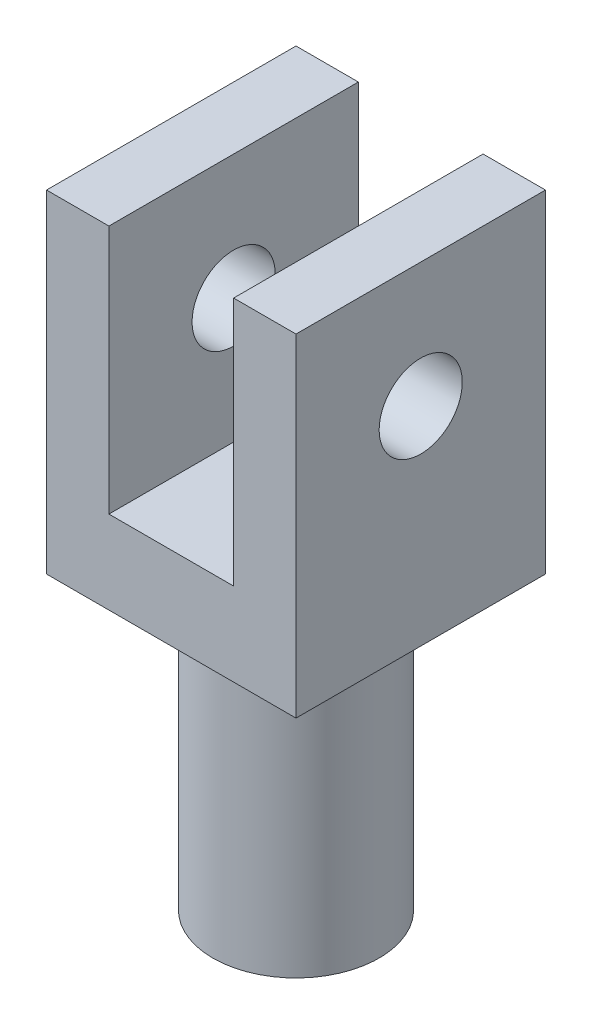
from build123d import *

# Parameters (mm, degrees)
ESQUISSE1_W             = 30
ESQUISSE1_H             = 40
BOSS_EXTRU_1_DEPTH      = 30
ESQUISSE2_W             = 15
ESQUISSE2_H             = 30
ENL_V_MAT_EXTRU_1_DEPTH = 30
ESQUISSE3_R             = 5
ENL_V_MAT_EXTRU_2_DEPTH = 50
ESQUISSE4_R             = 10
BOSS_EXTRU_2_DEPTH      = 35


with BuildPart() as part:
    # Esquisse1 → Boss.-Extru.1 (new body)
    with BuildSketch(Plane.XY):
        with Locations((-15, 20)):
            Rectangle(ESQUISSE1_W, ESQUISSE1_H)
    extrude(amount=BOSS_EXTRU_1_DEPTH)

    # Esquisse2 → Enlèv. mat.-Extru.1 (cut)
    with BuildSketch(Plane.XY.offset(30)):
        with Locations((-15, 25)):
            Rectangle(ESQUISSE2_W, ESQUISSE2_H)
    extrude(amount=-ENL_V_MAT_EXTRU_1_DEPTH, mode=Mode.SUBTRACT)

    # Esquisse3 → Enlèv. mat.-Extru.2 (cut)
    with BuildSketch(Plane.ZY.offset(30)):
        with Locations((15, 25)):
            Circle(ESQUISSE3_R)
    extrude(amount=-ENL_V_MAT_EXTRU_2_DEPTH, mode=Mode.SUBTRACT)

    # Esquisse4 → Boss.-Extru.2 (add)
    with BuildSketch(Plane.XZ):
        with Locations(Location((-15, 15, 0), (0, 0, 90))):  # turned: the seam where the file's is
            Circle(ESQUISSE4_R)
    extrude(amount=BOSS_EXTRU_2_DEPTH)


solid = part.part
